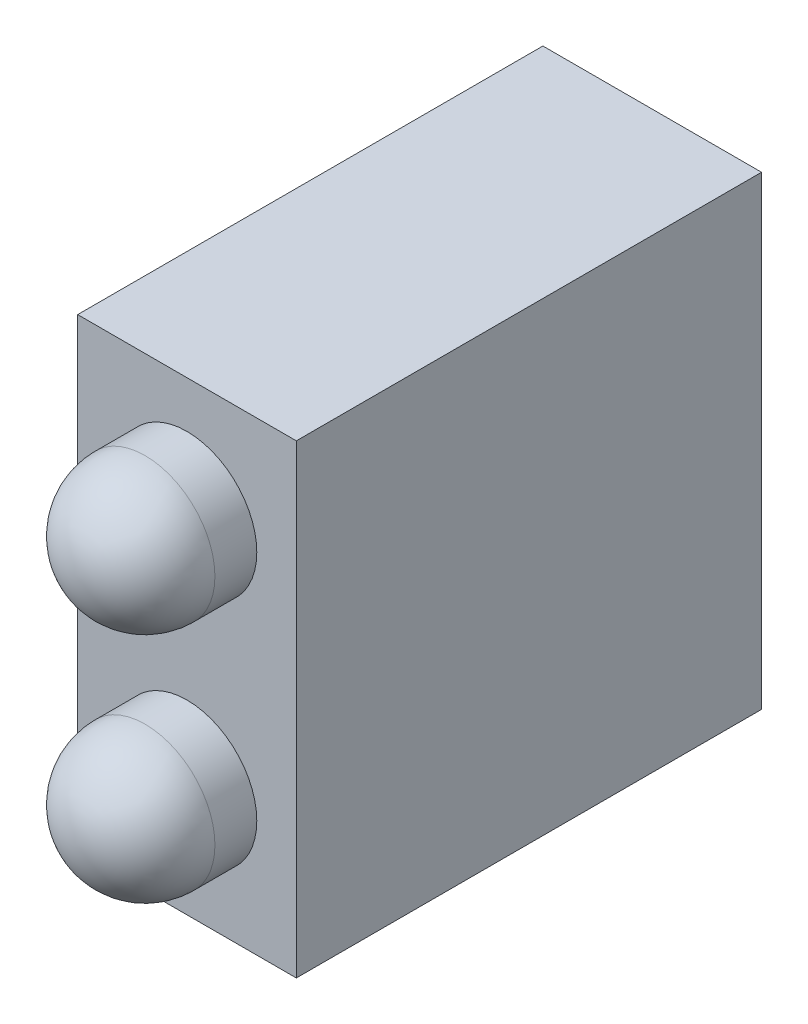
from build123d import *

# Parameters (mm, degrees)
CROQUIS1_W       = 4.7
CROQUIS1_H       = 10
EXTRUIR1_DEPTH   = 10
CROQUIS2_R       = 1.5
EXTRUIR2_DEPTH   = 2.4
EXTRUIR2_2_DEPTH = 2.4
REDONDEO1_R      = 1.5
REDONDEO2_R      = 1.5


with BuildPart() as part:
    # Croquis1 → Extruir1 (new body)
    with BuildSketch(Plane.XY):
        with Locations((2.35, 5)):
            Rectangle(CROQUIS1_W, CROQUIS1_H)
    extrude(amount=EXTRUIR1_DEPTH)


with BuildPart() as body_2:
    # Croquis2 → Extruir2 (new body)
    with BuildSketch(Plane.XY.offset(10)):
        with Locations((2.35, 7.5)):
            Circle(CROQUIS2_R)
    extrude(amount=EXTRUIR2_DEPTH)

    # Redondeo1
    redondeo1_edges = [body_2.edges().sort_by_distance(p)[0] for p in [
        (0.85, 7.5, 12.4),
    ]]
    fillet(redondeo1_edges, radius=REDONDEO1_R)


with BuildPart() as body_3:
    # Croquis2 → Extruir2 2 (new body)
    with BuildSketch(Plane.XY.offset(10)):
        with Locations((2.35, 2.5)):
            Circle(CROQUIS2_R)
    extrude(amount=EXTRUIR2_2_DEPTH)

    # Redondeo2
    redondeo2_edges = [body_3.edges().sort_by_distance(p)[0] for p in [
        (0.85, 2.5, 12.4),
    ]]
    fillet(redondeo2_edges, radius=REDONDEO2_R)


solid = Compound([part.part, body_2.part, body_3.part])
